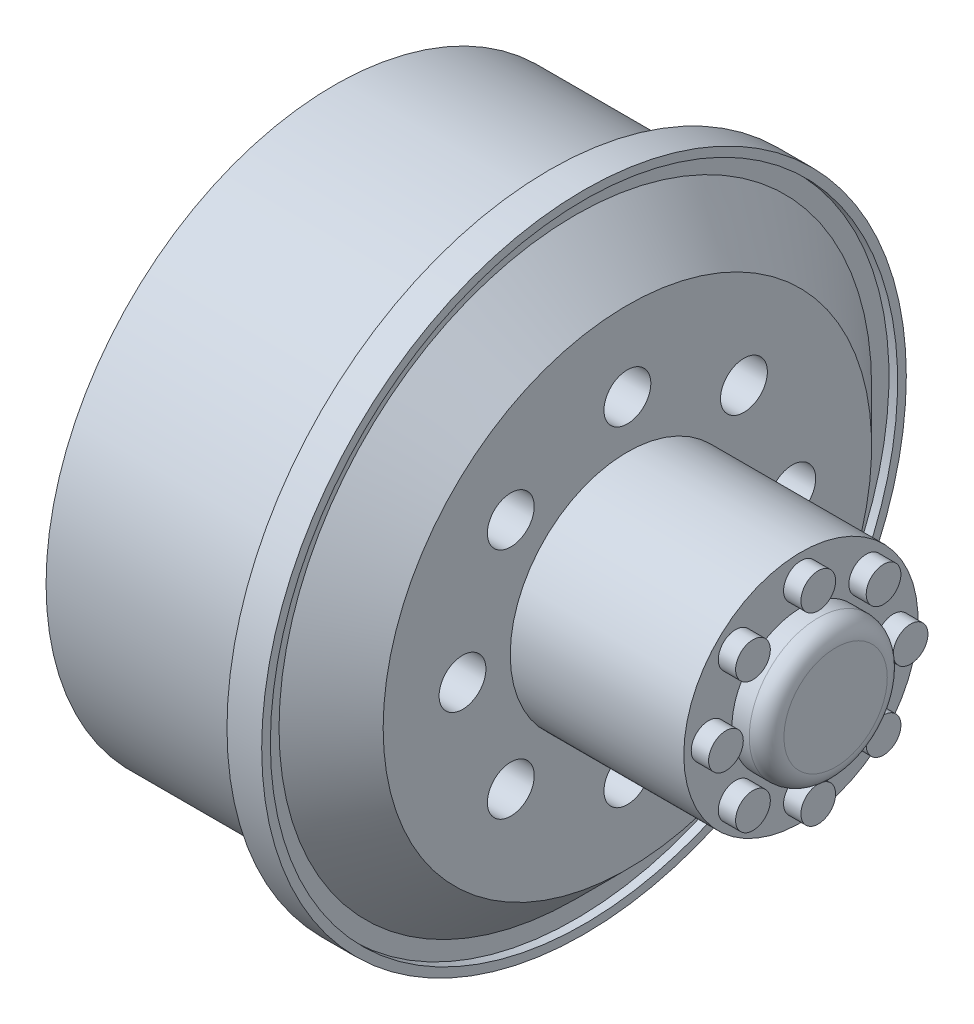
from build123d import *

# Parameters (mm, degrees)
SKETCH2_R           = 1.35
CUT_EXTRUDE1_DEPTH  = 10
SKETCH3_R           = 3.977137015
SKETCH3_R_2         = 1
BOSS_EXTRUDE1_DEPTH = 2
FILLET1_R           = 1
SKETCH4_R           = 1
CUT_EXTRUDE2_DEPTH  = 1


with BuildPart() as part:
    # Sketch1 → Revolve1 (revolve)
    with BuildSketch(Plane.XY):
        Polygon((-9.308622786, 16.6), (3.091377214, 16.6), (3.091377214, 18.57463979), (5.091377214, 18.57463979), (5.091377214, 18.07463979), (4.591377214, 18.07463979), (4.591377214, 17.07463979), (7.591377214, 14.07463979), (7.591377214, 6.75), (17.591377214, 6.75), (17.591377214, 0), (6.591377214, 0), (5.591377214, 0), (5.591377214, 13.246212665), (4.237589879, 14.6), (-9.308622786, 14.6), align=None)
    revolve(axis=Axis((-25, 0, 0), (1, 0, 0)))

    # Sketch2 → Cut-Extrude1 (cut)
    with BuildSketch(Plane.ZY.offset(-5.591377214)):
        with Locations((0, 9.5)):
            Circle(SKETCH2_R)
        with Locations((6.717514421, 6.717514421)):
            Circle(SKETCH2_R)
        with Locations((9.5, 0)):
            Circle(SKETCH2_R)
        with Locations((6.717514421, -6.717514421)):
            Circle(SKETCH2_R)
        with Locations((0, -9.5)):
            Circle(SKETCH2_R)
        with Locations((-6.717514421, -6.717514421)):
            Circle(SKETCH2_R)
        with Locations((-9.5, 0)):
            Circle(SKETCH2_R)
        with Locations((-6.717514421, 6.717514421)):
            Circle(SKETCH2_R)
    extrude(amount=-CUT_EXTRUDE1_DEPTH, mode=Mode.SUBTRACT)

    # Sketch3 → Boss-Extrude1 (add)
    with BuildSketch(Plane(origin=(17.591377214, 0, 0), x_dir=(0, 0, -1), z_dir=(1, 0, 0))):
        Circle(SKETCH3_R)
        with Locations((0, 5.320667936)):
            Circle(SKETCH3_R_2)
        with Locations((3.762280378, 3.762280378)):
            Circle(SKETCH3_R_2)
        with Locations((5.320667936, 0)):
            Circle(SKETCH3_R_2)
        with Locations((3.762280378, -3.762280378)):
            Circle(SKETCH3_R_2)
        with Locations((0, -5.320667936)):
            Circle(SKETCH3_R_2)
        with Locations((-3.762280378, -3.762280378)):
            Circle(SKETCH3_R_2)
        with Locations((-5.320667936, 0)):
            Circle(SKETCH3_R_2)
        with Locations((-3.762280378, 3.762280378)):
            Circle(SKETCH3_R_2)
    extrude(amount=BOSS_EXTRUDE1_DEPTH)

    # Fillet1
    fillet1_edges = [part.edges().sort_by_distance(p)[0] for p in [
        (19.591377214, 0, 3.977137015),
    ]]
    fillet(fillet1_edges, radius=FILLET1_R)

    # Sketch4 → Cut-Extrude2 (cut)
    with BuildSketch(Plane(origin=(19.591377214, 0, 0), x_dir=(0, 0, -1), z_dir=(1, 0, 0))):
        with Locations((0, 5.320667936)):
            Circle(SKETCH4_R)
        with Locations((3.762280378, 3.762280378)):
            Circle(SKETCH4_R)
        with Locations((5.320667936, 0)):
            Circle(SKETCH4_R)
        with Locations((3.762280378, -3.762280378)):
            Circle(SKETCH4_R)
        with Locations((0, -5.320667936)):
            Circle(SKETCH4_R)
        with Locations((-3.762280378, -3.762280378)):
            Circle(SKETCH4_R)
        with Locations((-5.320667936, 0)):
            Circle(SKETCH4_R)
        with Locations((-3.762280378, 3.762280378)):
            Circle(SKETCH4_R)
    extrude(amount=-CUT_EXTRUDE2_DEPTH, mode=Mode.SUBTRACT)


solid = part.part
